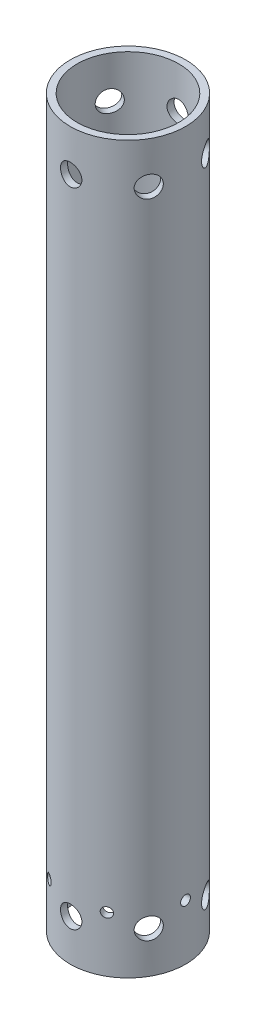
from build123d import *

# Parameters (mm, degrees)
SKETCH1_R                             = 39.6875
SKETCH1_R_2                           = 34.925
BOSS_EXTRUDE1_DEPTH                   = 498.602
F_37_64_0_57813_DIAMETER_HOLE3_REACH  = 508.438
F_37_64_0_57813_DIAMETER_HOLE3_BORE_R = 7.342251
CIRPATTERN1_COUNT                     = 6
CIRPATTERN2_COUNT                     = 6


with BuildPart() as part:
    # Sketch1 → Boss-Extrude1 (new body)
    with BuildSketch(Plane(origin=(0, 0, 0), x_dir=(1, 0, 0), z_dir=(0, 1, 0))):
        with Locations(Location((0, 0, 0), (0, 0, 270))):
            Circle(SKETCH1_R)
        with Locations(Location((0, 0, 0), (0, 0, 270))):
            Circle(SKETCH1_R_2, mode=Mode.SUBTRACT)
    extrude(amount=BOSS_EXTRUDE1_DEPTH)

    # 37_64 _0.57813_ Diameter Hole3 bore → 37_64 _0.57813_ Diameter Hole3 (cut, up to next)
    with BuildSketch(Plane.XY.offset(39.6875), mode=Mode.PRIVATE) as f_37_64_0_57813_diameter_hole3_sk1:
        with Locations((0, 470.027)):
            Circle(F_37_64_0_57813_DIAMETER_HOLE3_BORE_R)
    f_37_64_0_57813_diameter_hole3_tool1 = extrude(f_37_64_0_57813_diameter_hole3_sk1.sketch, amount=-F_37_64_0_57813_DIAMETER_HOLE3_REACH, mode=Mode.PRIVATE) & part.part
    # 37_64 _0.57813_ Diameter Hole3 bore → 37_64 _0.57813_ Diameter Hole3 (cut, up to next)
    with BuildSketch(Plane.XY.offset(39.6875), mode=Mode.PRIVATE) as f_37_64_0_57813_diameter_hole3_sk2:
        with Locations((0, 28.575)):
            Circle(F_37_64_0_57813_DIAMETER_HOLE3_BORE_R)
    f_37_64_0_57813_diameter_hole3_tool2 = extrude(f_37_64_0_57813_diameter_hole3_sk2.sketch, amount=-F_37_64_0_57813_DIAMETER_HOLE3_REACH, mode=Mode.PRIVATE) & part.part
    f_37_64_0_57813_diameter_hole3_1 = f_37_64_0_57813_diameter_hole3_tool1.solids().sort_by_distance((0, 470.027, 39.6875))[0]
    add(f_37_64_0_57813_diameter_hole3_1, mode=Mode.SUBTRACT)
    f_37_64_0_57813_diameter_hole3_2 = f_37_64_0_57813_diameter_hole3_tool2.solids().sort_by_distance((0, 28.575, 39.6875))[0]
    add(f_37_64_0_57813_diameter_hole3_2, mode=Mode.SUBTRACT)
    f_37_64_0_57813_diameter_hole3 = f_37_64_0_57813_diameter_hole3_1 + f_37_64_0_57813_diameter_hole3_2  # 37_64 _0.57813_ Diameter Hole3 as one shape, for the pattern or mirror that repeats it

    # CirPattern1: 37_64 _0.57813_ Diameter Hole3 ×6 about axis
    cirpattern1_axis = Axis((0, 498.602, 0), (0, -1, 0))
    for i in range(1, CIRPATTERN1_COUNT):
        add(f_37_64_0_57813_diameter_hole3.rotate(cirpattern1_axis, i * 360 / CIRPATTERN1_COUNT), mode=Mode.SUBTRACT)

    # Sketch9 → 1_4 Clearance Hole1 (revolve, cut)
    with BuildSketch(Plane(origin=(-39.6875, 38.1, 0), x_dir=(0, 0, 1), z_dir=(0, 1, 0))):
        Polygon((0, 0), (0, 18.031827343), (3.3782, 16.002), (3.3782, 0), align=None)
    f_1_4_clearance_hole1 = revolve(axis=Axis((-46.0375, 38.1, 0), (1, 0, 0)), mode=Mode.SUBTRACT)

    # CirPattern2: 1_4 Clearance Hole1 ×6 about axis
    cirpattern2_axis = Axis((0, 498.602, 0), (0, -1, 0))
    for i in range(1, CIRPATTERN2_COUNT):
        add(f_1_4_clearance_hole1.rotate(cirpattern2_axis, i * 360 / CIRPATTERN2_COUNT), mode=Mode.SUBTRACT)


solid = part.part
